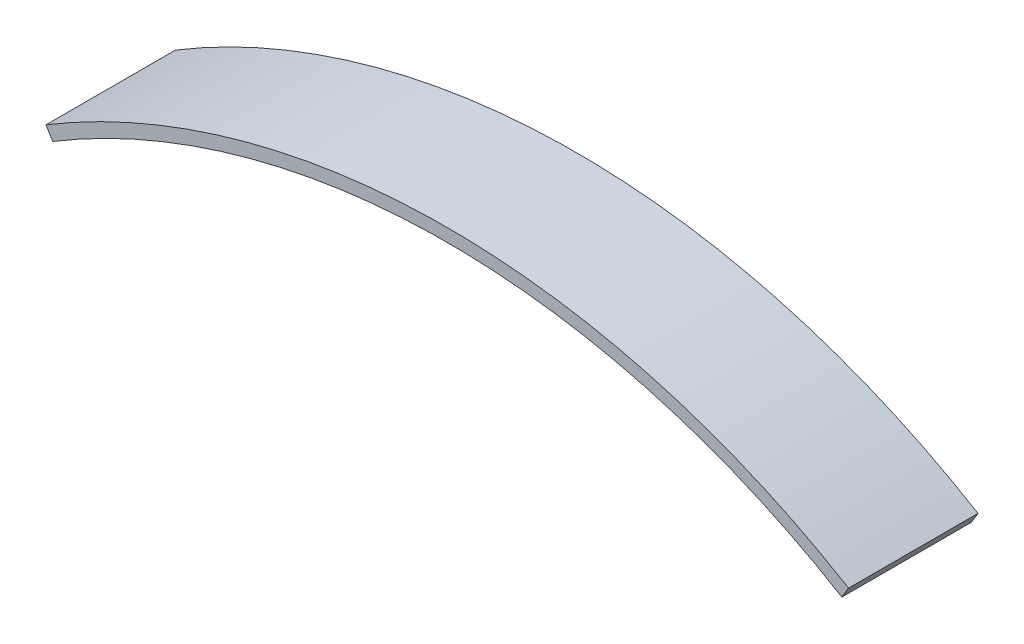
from build123d import *

# Parameters (mm, degrees)
EXTRUDE_THIN1_DEPTH = 10


with BuildPart() as part:
    # Sketch1 → Extrude-Thin1 (new body)
    with BuildSketch(Plane.XY):
        with BuildLine():
            ThreePointArc((0, 0), (31, 8.628801844), (62, 0))
            Line((62, 0), (61.483333333, -0.856186636))
            ThreePointArc((61.483333333, -0.856186636), (31, 7.628801844), (0.516666667, -0.856186636))
            Line((0.516666667, -0.856186636), (0, 0))
        make_face()
    extrude(amount=EXTRUDE_THIN1_DEPTH)


solid = part.part
